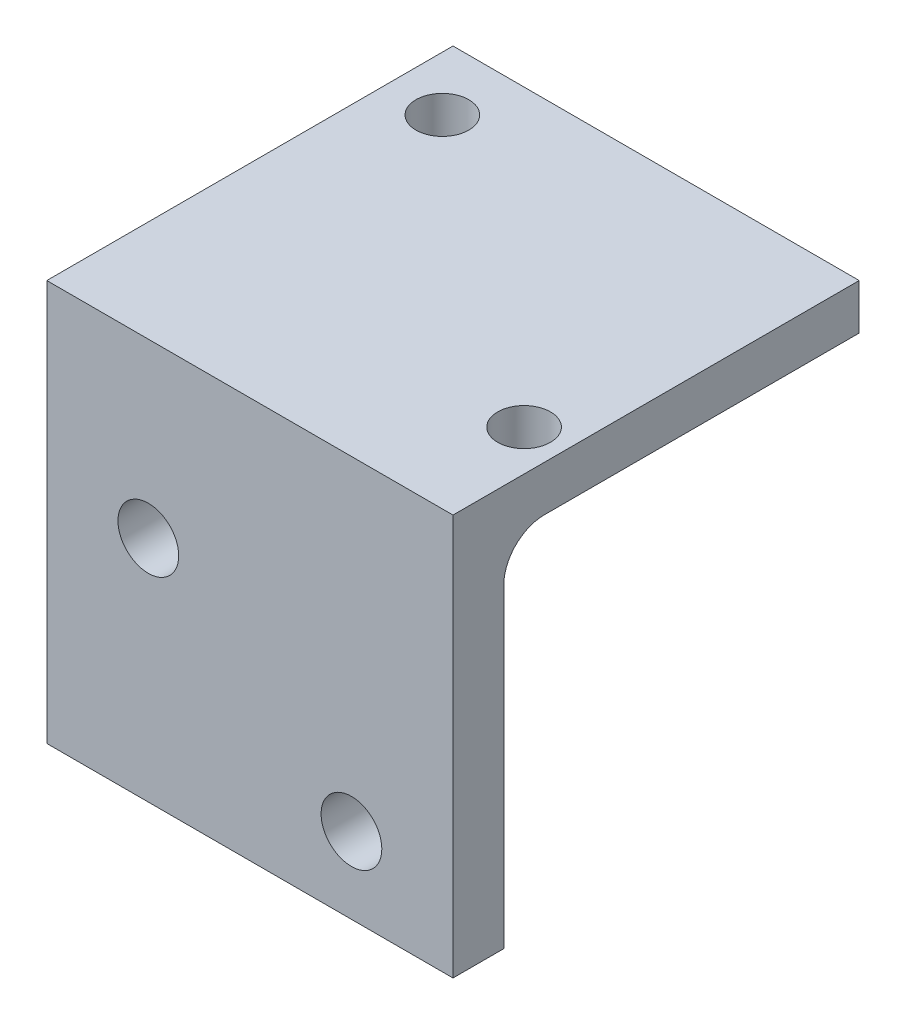
from build123d import *

# Parameters (mm, degrees)
SKETCH2_W                 = 25.4
SKETCH2_H                 = 25.4
SKETCH2_R                 = 1.651
BOSS_EXTRUDE1_DEPTH       = 2.8448
SKETCH3_W                 = 25.4
SKETCH3_H                 = 3.175
BOSS_EXTRUDE2_DEPTH       = 22.225
FILLET1_R                 = 2.54
F_6_CLEARANCE_HOLE1_D     = 3.7973
F_6_CLEARANCE_HOLE1_DEPTH = 12.7
F_6_CLEARANCE_HOLE1_TIP   = 1.140824014


with BuildPart() as part:
    # Sketch2 → Boss-Extrude1 (new body)
    with BuildSketch(Plane(origin=(0, 0, 0), x_dir=(1, 0, 0), z_dir=(0, 1, 0))):
        with Locations((-12.874879011, 6.594776819)):
            Rectangle(SKETCH2_W, SKETCH2_H)
        with Locations((-22.175738421, 15.230776819)):
            Circle(SKETCH2_R, mode=Mode.SUBTRACT)
        with Locations((-2.714879011, 0.879776819)):
            Circle(SKETCH2_R, mode=Mode.SUBTRACT)
    extrude(amount=BOSS_EXTRUDE1_DEPTH)

    # Sketch3 → Boss-Extrude2 (add)
    with BuildSketch(Plane(origin=(0, 0, 0), x_dir=(-1, 0, 0), z_dir=(0, -1, 0))):
        with Locations((12.874879011, -4.517723181)):
            Rectangle(SKETCH3_W, SKETCH3_H)
    extrude(amount=BOSS_EXTRUDE2_DEPTH)

    # Fillet1
    fillet1_edges = [part.edges().sort_by_distance(p)[0] for p in [
        (-12.874879011, 0, 2.930223181),
    ]]
    fillet(fillet1_edges, radius=FILLET1_R)

    # #6 Clearance Hole1
    with Locations(Plane(origin=(-6.524879011, -17.4625, 2.930223181), x_dir=(-1, 0, 0), z_dir=(0, 0, -1))):
        with Locations((0, 0), (12.7, 9.525)):
            Hole(F_6_CLEARANCE_HOLE1_D / 2, depth=F_6_CLEARANCE_HOLE1_DEPTH)
            with Locations((0, 0, -(F_6_CLEARANCE_HOLE1_DEPTH + F_6_CLEARANCE_HOLE1_TIP / 2))):  # 118° drill point
                Cone(0, F_6_CLEARANCE_HOLE1_D / 2, F_6_CLEARANCE_HOLE1_TIP, mode=Mode.SUBTRACT)


solid = part.part
